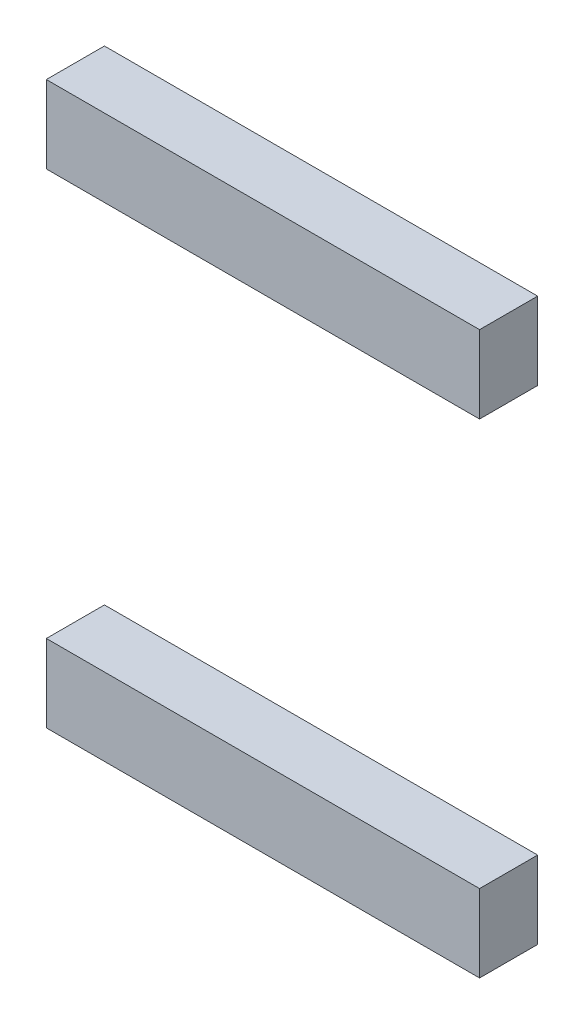
from build123d import *

# Parameters (mm, degrees)
SKETCH2_W             = 22.375
SKETCH2_H             = 4
BOSS_EXTRUDE1_DEPTH   = 3
BOSS_EXTRUDE1_2_DEPTH = 3


with BuildPart() as part:
    # Sketch2 → Boss-Extrude1 (new body)
    with BuildSketch(Plane(origin=(0, 0, 0), x_dir=(-1, 0, 0), z_dir=(0, 0, 1))):
        with Locations((11.5625, -33.5)):
            Rectangle(SKETCH2_W, SKETCH2_H)
    extrude(amount=BOSS_EXTRUDE1_DEPTH)


with BuildPart() as body_2:
    # Sketch2 → Boss-Extrude1 2 (new body)
    with BuildSketch(Plane(origin=(0, 0, 0), x_dir=(-1, 0, 0), z_dir=(0, 0, 1))):
        with Locations((11.5625, -8.5)):
            Rectangle(SKETCH2_W, SKETCH2_H)
    extrude(amount=BOSS_EXTRUDE1_2_DEPTH)


solid = Compound([part.part, body_2.part])
